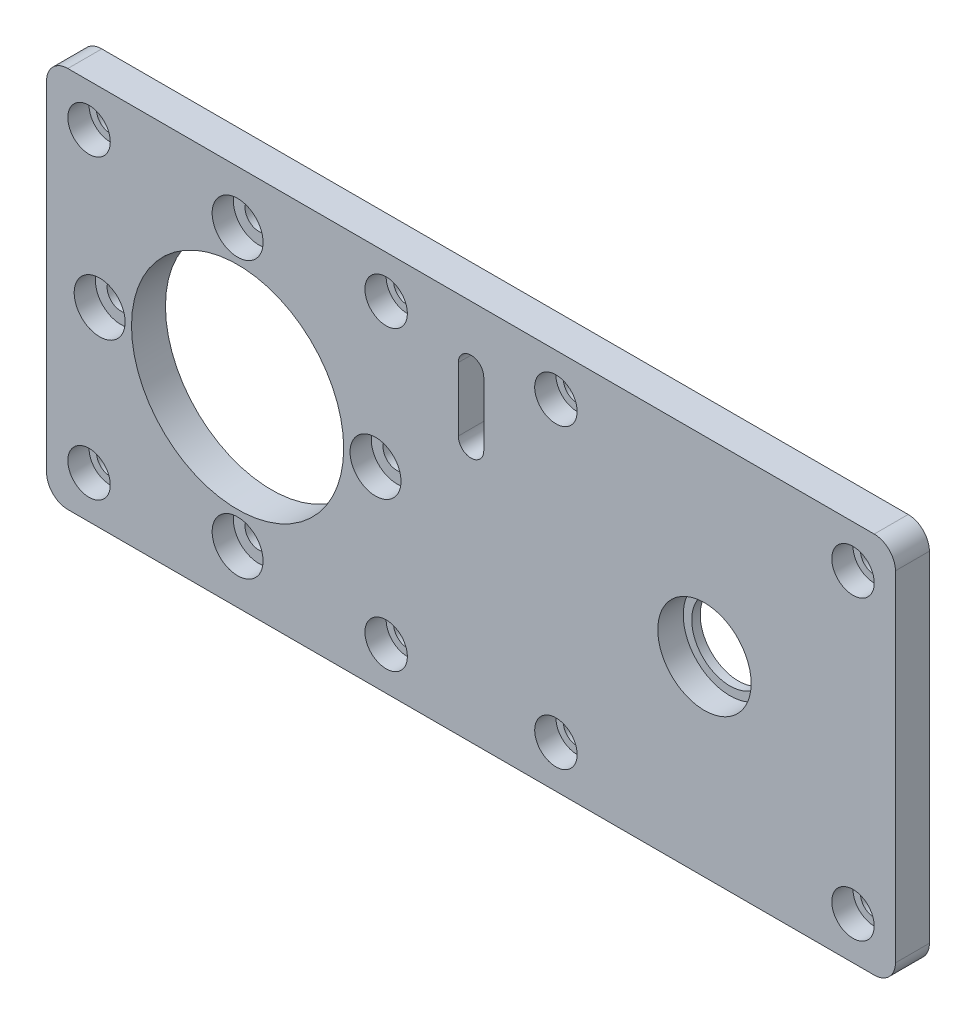
from build123d import *

# Parameters (mm, degrees)
SKETCH1_W           = 200
SKETCH1_H           = 90
SKETCH1_R           = 25
SKETCH1_R_2         = 3.25
SKETCH1_R_3         = 9
BOSS_EXTRUDE1_DEPTH = 4
FILLET1_R           = 5
SKETCH2_R           = 11
CUT_EXTRUDE1_DEPTH  = 6
SKETCH3_R           = 5
SKETCH3_R_2         = 6
CUT_EXTRUDE2_DEPTH  = 5


with BuildPart() as part:
    # Sketch1 → Boss-Extrude1 (new body, symmetric)
    with BuildSketch(Plane.XY):
        Rectangle(SKETCH1_W, SKETCH1_H)
        with Locations((-55, 0)):
            Circle(SKETCH1_R, mode=Mode.SUBTRACT)
        with Locations((-55, 32.5)):
            Circle(SKETCH1_R_2, mode=Mode.SUBTRACT)
        with Locations((-55, -32.5)):
            Circle(SKETCH1_R_2, mode=Mode.SUBTRACT)
        with Locations((-87.5, 0)):
            Circle(SKETCH1_R_2, mode=Mode.SUBTRACT)
        with Locations((-22.5, 0)):
            Circle(SKETCH1_R_2, mode=Mode.SUBTRACT)
        with Locations((55, 0)):
            Circle(SKETCH1_R_3, mode=Mode.SUBTRACT)
        with Locations((-90, 35)):
            Circle(SKETCH1_R_2, mode=Mode.SUBTRACT)
        with Locations((-20, 35)):
            Circle(SKETCH1_R_2, mode=Mode.SUBTRACT)
        with Locations((-90, -35)):
            Circle(SKETCH1_R_2, mode=Mode.SUBTRACT)
        with Locations((-20, -35)):
            Circle(SKETCH1_R_2, mode=Mode.SUBTRACT)
        with Locations((90, -35)):
            Circle(SKETCH1_R_2, mode=Mode.SUBTRACT)
        with Locations((20, -35)):
            Circle(SKETCH1_R_2, mode=Mode.SUBTRACT)
        with Locations((20, 35)):
            Circle(SKETCH1_R_2, mode=Mode.SUBTRACT)
        with Locations((90, 35)):
            Circle(SKETCH1_R_2, mode=Mode.SUBTRACT)
        with BuildLine():
            Line((3, 31), (3, 16))
            ThreePointArc((3, 16), (0, 13), (-3, 16))
            Line((-3, 16), (-3, 31))
            ThreePointArc((-3, 31), (0, 34), (3, 31))
        make_face(mode=Mode.SUBTRACT)
    extrude(amount=BOSS_EXTRUDE1_DEPTH, both=True)

    # Fillet1
    fillet1_edges = [part.edges().sort_by_distance(p)[0] for p in [
        (100, -45, 0),
        (-100, -45, 0),
        (-100, 45, 0),
        (100, 45, 0),
    ]]
    fillet(fillet1_edges, radius=FILLET1_R)

    # Sketch2 → Cut-Extrude1 (cut)
    with BuildSketch(Plane.XY.offset(4)):
        with Locations((55, 0)):
            Circle(SKETCH2_R)
    extrude(amount=-CUT_EXTRUDE1_DEPTH, mode=Mode.SUBTRACT)

    # Sketch3 → Cut-Extrude2 (cut)
    with BuildSketch(Plane.XY.offset(4)):
        with Locations((-90, 35)):
            Circle(SKETCH3_R)
        with Locations((-20, 35)):
            Circle(SKETCH3_R)
        with Locations((-90, -35)):
            Circle(SKETCH3_R)
        with Locations((-20, -35)):
            Circle(SKETCH3_R)
        with Locations((20, -35)):
            Circle(SKETCH3_R)
        with Locations((90, -35)):
            Circle(SKETCH3_R)
        with Locations((90, 35)):
            Circle(SKETCH3_R)
        with Locations((20, 35)):
            Circle(SKETCH3_R)
        with Locations((-55, 32.5)):
            Circle(SKETCH3_R_2)
        with Locations((-87.5, 0)):
            Circle(SKETCH3_R_2)
        with Locations((-55, -32.5)):
            Circle(SKETCH3_R_2)
        with Locations((-22.5, 0)):
            Circle(SKETCH3_R_2)
    extrude(amount=-CUT_EXTRUDE2_DEPTH, mode=Mode.SUBTRACT)


solid = part.part
